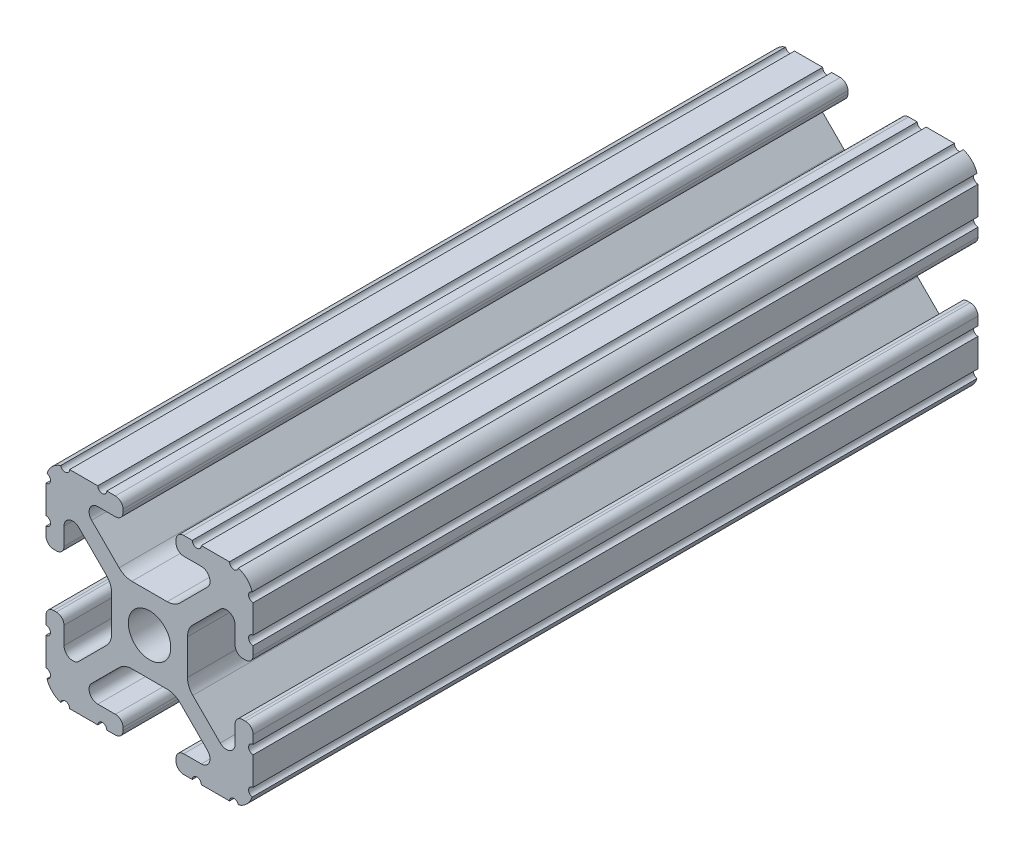
from build123d import *

# Parameters (mm, degrees)
BOSS_EXTRUDE1_DEPTH     = 63.5
SKETCH5_R               = 0.55245
CUT_EXTRUDE1_DEPTH      = 64.5
CUT_EXTRUDE1_DEPTH_BACK = 64.5
SKETCH7_W               = 25.4
SKETCH7_H               = 38.1
CUT_EXTRUDE2_DEPTH      = 12.7


with BuildPart() as part:
    # Sketch4 → Boss-Extrude1 (new body, symmetric)
    with BuildSketch(Plane.XY):
        with BuildLine():
            Line((4.190365, -12.7), (10.11729625, -12.7))
            ThreePointArc((10.11729625, -12.7), (11.943543585, -11.943543585), (12.7, -10.11729625))
            Line((12.7, -10.11729625), (12.7, -4.190365))
            ThreePointArc((12.7, -4.190365), (12.42492494, -3.52627506), (11.760835, -3.2512))
            Line((11.760835, -3.2512), (11.429365, -3.2512))
            ThreePointArc((11.429365, -3.2512), (10.76527506, -3.52627506), (10.4902, -4.190365))
            Line((10.4902, -4.190365), (10.4902, -6.348478019))
            ThreePointArc((10.4902, -6.348478019), (9.830707141, -7.335478831), (8.666460301, -7.103895736))
            Line((8.666460301, -7.103895736), (5.299899128, -3.737334563))
            ThreePointArc((5.299899128, -3.737334563), (4.817571085, -3.015479634), (4.6482, -2.16399369))
            Line((4.6482, -2.16399369), (4.6482, 0))
            Line((4.6482, 0), (2.6035, 0))
            ThreePointArc((2.6035, 0), (1.840952505, -1.840952505), (0, -2.6035))
            Line((0, -2.6035), (0, -4.6482))
            Line((0, -4.6482), (2.16399369, -4.6482))
            ThreePointArc((2.16399369, -4.6482), (3.015479634, -4.817571085), (3.737334563, -5.299899128))
            Line((3.737334563, -5.299899128), (7.103895736, -8.666460301))
            ThreePointArc((7.103895736, -8.666460301), (7.335478831, -9.830707141), (6.348478019, -10.4902))
            Line((6.348478019, -10.4902), (4.190365, -10.4902))
            ThreePointArc((4.190365, -10.4902), (3.52627506, -10.76527506), (3.2512, -11.429365))
            Line((3.2512, -11.429365), (3.2512, -11.760835))
            ThreePointArc((3.2512, -11.760835), (3.52627506, -12.42492494), (4.190365, -12.7))
        make_face()
    extrude(amount=BOSS_EXTRUDE1_DEPTH, both=True)

    # Sketch5 → Cut-Extrude1 (cut, two sides)
    with BuildSketch(Plane.XY) as cut_extrude1_sk:
        with Locations((10.356153152, -12.7)):
            Circle(SKETCH5_R)
        with Locations((5.796028019, -12.7)):
            Circle(SKETCH5_R)
        with Locations((12.7, -10.356153152)):
            Circle(SKETCH5_R)
        with Locations((12.7, -5.796028019)):
            Circle(SKETCH5_R)
    extrude(amount=CUT_EXTRUDE1_DEPTH, mode=Mode.SUBTRACT)
    extrude(cut_extrude1_sk.sketch, amount=-CUT_EXTRUDE1_DEPTH_BACK, mode=Mode.SUBTRACT)

    # Mirror1: part across plane


with BuildPart() as part_1:
    add(part.part)
    add(part.part.mirror(Plane(origin=(0, 0, 0), x_dir=(0, 0, 1), z_dir=(1, 0, 0))))

    # Mirror2: part across plane


with BuildPart() as part_2:
    add(part_1.part)
    add(part_1.part.mirror(Plane.ZX))

    # Sketch7 → Cut-Extrude2 (cut, symmetric)
    with BuildSketch(Plane(origin=(0, 0, 0), x_dir=(1, 0, 0), z_dir=(0, 1, 0))):
        with Locations((0, -44.45)):
            Rectangle(SKETCH7_W, SKETCH7_H)
    extrude(amount=CUT_EXTRUDE2_DEPTH, both=True, mode=Mode.SUBTRACT)


solid = part_2.part
